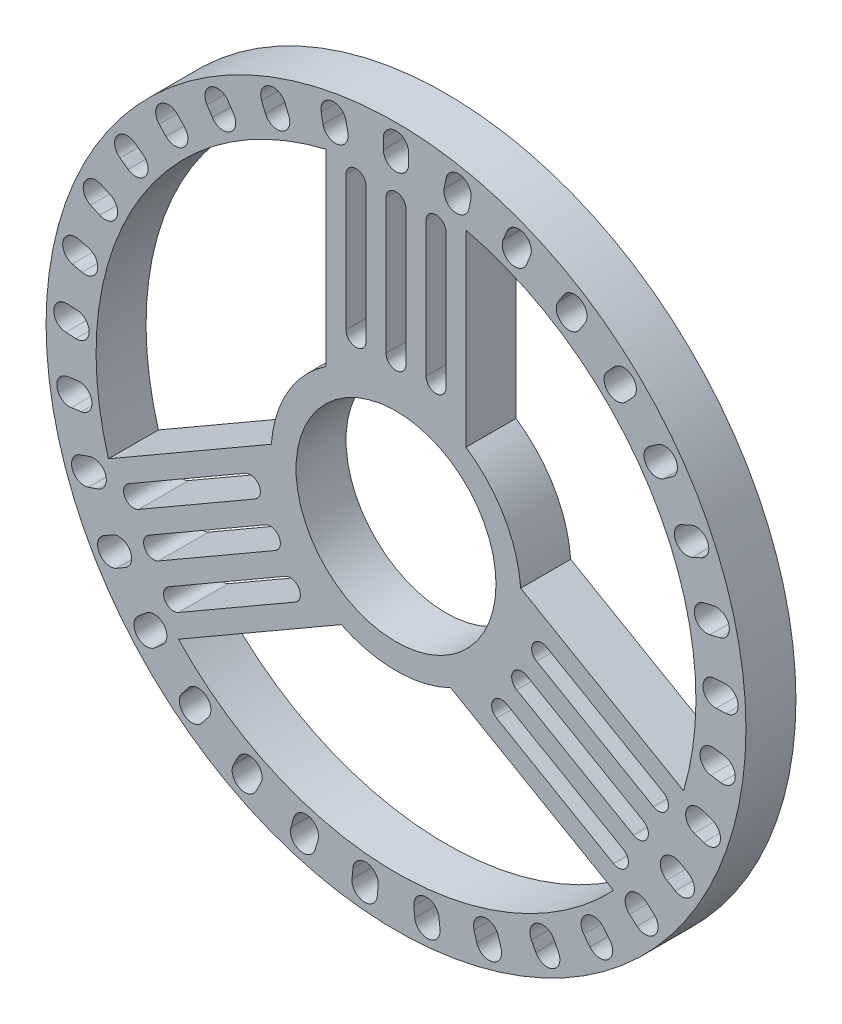
from build123d import *

# Parameters (mm, degrees)
SKETCH_1_R      = 17.5
SKETCH_1_R_2    = 5
EXTRUDE_2_DEPTH = 2.5


with BuildPart() as part:
    # 草图1 → 凸台-拉伸2 (new body)
    with BuildSketch(Plane.XY):
        Circle(SKETCH_1_R)
        with BuildLine():
            Line((14.381805097, -4.26188716), (6.234347779, 0.442049516))
            ThreePointArc((6.234347779, 0.442049516), (5.412658774, 3.125), (3.5, 5.178078794))
            Line((3.5, 5.178078794), (3.5, 14.585952146))
            ThreePointArc((3.5, 14.585952146), (12.990381057, 7.5), (14.381805097, -4.26188716))
        make_face(mode=Mode.SUBTRACT)
        with BuildLine():
            Line((2.734347779, -5.62012831), (10.881805097, -10.324064986))
            ThreePointArc((10.881805097, -10.324064986), (0, -15), (-10.881805097, -10.324064986))
            Line((-10.881805097, -10.324064986), (-2.734347779, -5.62012831))
            ThreePointArc((-2.734347779, -5.62012831), (0, -6.25), (2.734347779, -5.62012831))
        make_face(mode=Mode.SUBTRACT)
        with BuildLine():
            Line((-3.5, 14.585952146), (-3.5, 5.178078794))
            ThreePointArc((-3.5, 5.178078794), (-5.412658774, 3.125), (-6.234347779, 0.442049516))
            Line((-6.234347779, 0.442049516), (-14.381805097, -4.26188716))
            ThreePointArc((-14.381805097, -4.26188716), (-12.990381057, 7.5), (-3.5, 14.585952146))
        make_face(mode=Mode.SUBTRACT)
        with BuildLine():
            Line((-11.373072369, -8.299039919), (-5.532643333, -4.927066643))
            ThreePointArc((-5.532643333, -4.927066643), (-4.850509276, -5.109843913), (-5.033286546, -5.79197797))
            Line((-5.033286546, -5.79197797), (-10.873715582, -9.163951246))
            ThreePointArc((-10.873715582, -9.163951246), (-11.555849639, -8.981173976), (-11.373072369, -8.299039919))
        make_face(mode=Mode.SUBTRACT)
        with BuildLine():
            ThreePointArc((-11.873715582, -7.431900439), (-12.555849639, -7.249123169), (-12.373072369, -6.566989112))
            Line((-12.373072369, -6.566989112), (-6.532643333, -3.195015836))
            ThreePointArc((-6.532643333, -3.195015836), (-5.850509276, -3.377793105), (-6.033286546, -4.059927163))
            Line((-6.033286546, -4.059927163), (-11.873715582, -7.431900439))
        make_face(mode=Mode.SUBTRACT)
        with BuildLine():
            ThreePointArc((-12.873715582, -5.699849631), (-13.555849639, -5.517072361), (-13.373072369, -4.834938304))
            Line((-13.373072369, -4.834938304), (-7.532643333, -1.462965028))
            ThreePointArc((-7.532643333, -1.462965028), (-6.850509276, -1.645742298), (-7.033286546, -2.327876355))
            Line((-7.033286546, -2.327876355), (-12.873715582, -5.699849631))
        make_face(mode=Mode.SUBTRACT)
        with BuildLine():
            ThreePointArc((11.373072369, -8.299039919), (11.555849639, -8.981173976), (10.873715582, -9.163951246))
            Line((10.873715582, -9.163951246), (5.033286546, -5.79197797))
            ThreePointArc((5.033286546, -5.79197797), (4.850509276, -5.109843913), (5.532643333, -4.927066643))
            Line((5.532643333, -4.927066643), (11.373072369, -8.299039919))
        make_face(mode=Mode.SUBTRACT)
        with BuildLine():
            ThreePointArc((12.373072369, -6.566989112), (12.555849639, -7.249123169), (11.873715582, -7.431900439))
            Line((11.873715582, -7.431900439), (6.033286546, -4.059927163))
            ThreePointArc((6.033286546, -4.059927163), (5.850509276, -3.377793105), (6.532643333, -3.195015836))
            Line((6.532643333, -3.195015836), (12.373072369, -6.566989112))
        make_face(mode=Mode.SUBTRACT)
        with BuildLine():
            ThreePointArc((13.373072369, -4.834938304), (13.555849639, -5.517072361), (12.873715582, -5.699849631))
            Line((12.873715582, -5.699849631), (7.033286546, -2.327876355))
            ThreePointArc((7.033286546, -2.327876355), (6.850509276, -1.645742298), (7.532643333, -1.462965028))
            Line((7.532643333, -1.462965028), (13.373072369, -4.834938304))
        make_face(mode=Mode.SUBTRACT)
        Circle(SKETCH_1_R_2, mode=Mode.SUBTRACT)
        with BuildLine():
            ThreePointArc((-2.499356787, 13.99888955), (-2, 14.498246338), (-1.500643213, 13.99888955))
            Line((-1.500643213, 13.99888955), (-1.500643213, 7.254942998))
            ThreePointArc((-1.500643213, 7.254942998), (-2, 6.755586211), (-2.499356787, 7.254942998))
            Line((-2.499356787, 7.254942998), (-2.499356787, 13.99888955))
        make_face(mode=Mode.SUBTRACT)
        with BuildLine():
            ThreePointArc((-0.499356787, 13.99888955), (0, 14.498246338), (0.499356787, 13.99888955))
            Line((0.499356787, 13.99888955), (0.499356787, 7.254942998))
            ThreePointArc((0.499356787, 7.254942998), (0, 6.755586211), (-0.499356787, 7.254942998))
            Line((-0.499356787, 7.254942998), (-0.499356787, 13.99888955))
        make_face(mode=Mode.SUBTRACT)
        with BuildLine():
            Line((2.499356787, 13.99888955), (2.499356787, 7.254942998))
            ThreePointArc((2.499356787, 7.254942998), (2, 6.755586211), (1.500643213, 7.254942998))
            Line((1.500643213, 7.254942998), (1.500643213, 13.99888955))
            ThreePointArc((1.500643213, 13.99888955), (2, 14.498246338), (2.499356787, 13.99888955))
        make_face(mode=Mode.SUBTRACT)
        with BuildLine():
            ThreePointArc((-9.701417984, -13.361669033), (-10.591416242, -13.468081352), (-10.697828562, -12.578083094))
            Line((-10.697828562, -12.578083094), (-10.388749068, -12.185056546))
            ThreePointArc((-10.388749068, -12.185056546), (-9.49875081, -12.078644227), (-9.392338491, -12.968642486))
            Line((-9.392338491, -12.968642486), (-9.701417984, -13.361669033))
        make_face(mode=Mode.SUBTRACT)
        with BuildLine():
            ThreePointArc((-12.054813214, -11.284200841), (-12.948866708, -11.220256873), (-12.88492274, -10.326203379))
            Line((-12.88492274, -10.326203379), (-12.507047953, -9.998773012))
            ThreePointArc((-12.507047953, -9.998773012), (-11.612994459, -10.06271698), (-11.676938426, -10.956770474))
            Line((-11.676938426, -10.956770474), (-12.054813214, -11.284200841))
        make_face(mode=Mode.SUBTRACT)
        with BuildLine():
            ThreePointArc((-4.040454636, -16.010197893), (-4.827151016, -16.439766616), (-5.256719739, -15.653070236))
            Line((-5.256719739, -15.653070236), (-5.115853461, -15.17332375))
            ThreePointArc((-5.115853461, -15.17332375), (-4.329157081, -14.743755026), (-3.899588358, -15.530451406))
            Line((-3.899588358, -15.530451406), (-4.040454636, -16.010197893))
        make_face(mode=Mode.SUBTRACT)
        with BuildLine():
            ThreePointArc((-6.997388231, -14.956211692), (-7.851164398, -15.22913428), (-8.124086986, -14.375358113))
            Line((-8.124086986, -14.375358113), (-7.894973725, -13.930940389))
            ThreePointArc((-7.894973725, -13.930940389), (-7.041197558, -13.658017801), (-6.76827497, -14.511793968))
            Line((-6.76827497, -14.511793968), (-6.997388231, -14.956211692))
        make_face(mode=Mode.SUBTRACT)
        with BuildLine():
            ThreePointArc((-0.937488484, -16.485533828), (-1.62867182, -17.056222953), (-2.199360945, -16.365039617))
            Line((-2.199360945, -16.365039617), (-2.151832924, -15.867303656))
            ThreePointArc((-2.151832924, -15.867303656), (-1.460649588, -15.29661453), (-0.889960462, -15.987797866))
            Line((-0.889960462, -15.987797866), (-0.937488484, -16.485533828))
        make_face(mode=Mode.SUBTRACT)
        with BuildLine():
            ThreePointArc((-13.972516085, -8.79889223), (-14.838311393, -8.566903077), (-14.606322239, -7.70110777))
            Line((-14.606322239, -7.70110777), (-14.173309538, -7.45110777))
            ThreePointArc((-14.173309538, -7.45110777), (-13.30751423, -7.683096923), (-13.539503384, -8.54889223))
            Line((-13.539503384, -8.54889223), (-13.972516085, -8.79889223))
        make_face(mode=Mode.SUBTRACT)
        with BuildLine():
            ThreePointArc((-15.385215821, -5.995568729), (-16.191460843, -5.603919083), (-15.799811197, -4.79767406))
            Line((-15.799811197, -4.79767406), (-15.327310787, -4.634140079))
            ThreePointArc((-15.327310787, -4.634140079), (-14.521065765, -5.025789725), (-14.912715411, -5.832034748))
            Line((-14.912715411, -5.832034748), (-15.385215821, -5.995568729))
        make_face(mode=Mode.SUBTRACT)
        with BuildLine():
            ThreePointArc((-16.241853771, -2.975549753), (-16.959408712, -2.438394852), (-16.422253811, -1.72083991))
            Line((-16.422253811, -1.72083991), (-15.92734309, -1.649682491))
            ThreePointArc((-15.92734309, -1.649682491), (-15.209788149, -2.186837392), (-15.74694305, -2.904392334))
            Line((-15.74694305, -2.904392334), (-16.241853771, -2.975549753))
        make_face(mode=Mode.SUBTRACT)
        with BuildLine():
            ThreePointArc((2.199360945, -16.365039617), (1.62867182, -17.056222953), (0.937488484, -16.485533828))
            Line((0.937488484, -16.485533828), (0.889960462, -15.987797866))
            ThreePointArc((0.889960462, -15.987797866), (1.460649588, -15.29661453), (2.151832924, -15.867303656))
            Line((2.151832924, -15.867303656), (2.199360945, -16.365039617))
        make_face(mode=Mode.SUBTRACT)
        with BuildLine():
            ThreePointArc((5.256719739, -15.653070236), (4.827151016, -16.439766616), (4.040454636, -16.010197893))
            Line((4.040454636, -16.010197893), (3.899588358, -15.530451406))
            ThreePointArc((3.899588358, -15.530451406), (4.329157081, -14.743755026), (5.115853461, -15.17332375))
            Line((5.115853461, -15.17332375), (5.256719739, -15.653070236))
        make_face(mode=Mode.SUBTRACT)
        with BuildLine():
            ThreePointArc((8.124086986, -14.375358113), (7.851164398, -15.22913428), (6.997388231, -14.956211692))
            Line((6.997388231, -14.956211692), (6.76827497, -14.511793968))
            ThreePointArc((6.76827497, -14.511793968), (7.041197558, -13.658017801), (7.894973725, -13.930940389))
            Line((7.894973725, -13.930940389), (8.124086986, -14.375358113))
        make_face(mode=Mode.SUBTRACT)
        with BuildLine():
            ThreePointArc((10.697828562, -12.578083094), (10.591416242, -13.468081352), (9.701417984, -13.361669033))
            Line((9.701417984, -13.361669033), (9.392338491, -12.968642486))
            ThreePointArc((9.392338491, -12.968642486), (9.49875081, -12.078644227), (10.388749068, -12.185056546))
            Line((10.388749068, -12.185056546), (10.697828562, -12.578083094))
        make_face(mode=Mode.SUBTRACT)
        with BuildLine():
            ThreePointArc((12.88492274, -10.326203379), (12.948866708, -11.220256873), (12.054813214, -11.284200841))
            Line((12.054813214, -11.284200841), (11.676938426, -10.956770474))
            ThreePointArc((11.676938426, -10.956770474), (11.612994459, -10.06271698), (12.507047953, -9.998773012))
            Line((12.507047953, -9.998773012), (12.88492274, -10.326203379))
        make_face(mode=Mode.SUBTRACT)
        with BuildLine():
            ThreePointArc((14.606322239, -7.70110777), (14.838311393, -8.566903077), (13.972516085, -8.79889223))
            Line((13.972516085, -8.79889223), (13.539503384, -8.54889223))
            ThreePointArc((13.539503384, -8.54889223), (13.30751423, -7.683096923), (14.173309538, -7.45110777))
            Line((14.173309538, -7.45110777), (14.606322239, -7.70110777))
        make_face(mode=Mode.SUBTRACT)
        with BuildLine():
            ThreePointArc((15.799811197, -4.79767406), (16.191460843, -5.603919083), (15.385215821, -5.995568729))
            Line((15.385215821, -5.995568729), (14.912715411, -5.832034748))
            ThreePointArc((14.912715411, -5.832034748), (14.521065765, -5.025789725), (15.327310787, -4.634140079))
            Line((15.327310787, -4.634140079), (15.799811197, -4.79767406))
        make_face(mode=Mode.SUBTRACT)
        with BuildLine():
            ThreePointArc((16.422253811, -1.72083991), (16.959408712, -2.438394852), (16.241853771, -2.975549753))
            Line((16.241853771, -2.975549753), (15.74694305, -2.904392334))
            ThreePointArc((15.74694305, -2.904392334), (15.209788149, -2.186837392), (15.92734309, -1.649682491))
            Line((15.92734309, -1.649682491), (16.422253811, -1.72083991))
        make_face(mode=Mode.SUBTRACT)
        with BuildLine():
            ThreePointArc((-16.511468808, 0.152013344), (-17.114399363, 0.815259322), (-16.451153385, 1.418189878))
            Line((-16.451153385, 1.418189878), (-15.951719716, 1.39439892))
            ThreePointArc((-15.951719716, 1.39439892), (-15.34878916, 0.731152942), (-16.012035138, 0.128222387))
            Line((-16.012035138, 0.128222387), (-16.511468808, 0.152013344))
        make_face(mode=Mode.SUBTRACT)
        with BuildLine():
            ThreePointArc((-16.184316342, 3.274082283), (-16.65083103, 4.0394479), (-15.885465413, 4.505962588))
            Line((-15.885465413, 4.505962588), (-15.399559629, 4.388083121))
            ThreePointArc((-15.399559629, 4.388083121), (-14.933044941, 3.622717504), (-15.698410557, 3.156202816))
            Line((-15.698410557, 3.156202816), (-16.184316342, 3.274082283))
        make_face(mode=Mode.SUBTRACT)
        with BuildLine():
            ThreePointArc((-15.272220515, 6.277817358), (-15.58545828, 7.117640306), (-14.745635332, 7.430878071))
            Line((-14.745635332, 7.430878071), (-14.290819334, 7.223170565))
            ThreePointArc((-14.290819334, 7.223170565), (-13.977581569, 6.383347616), (-14.817404517, 6.070109851))
            Line((-14.817404517, 6.070109851), (-15.272220515, 6.277817358))
        make_face(mode=Mode.SUBTRACT)
        with BuildLine():
            ThreePointArc((-13.808146848, 9.054655757), (-13.95678646, 9.938582647), (-13.07285957, 10.087222259))
            Line((-13.07285957, 10.087222259), (-12.665571594, 9.797193804))
            ThreePointArc((-12.665571594, 9.797193804), (-12.516931981, 8.913266914), (-13.400858872, 8.764627302))
            Line((-13.400858872, 8.764627302), (-13.808146848, 9.054655757))
        make_face(mode=Mode.SUBTRACT)
        with BuildLine():
            ThreePointArc((-11.845010777, 11.504235304), (-11.823680014, 12.400318716), (-10.927596602, 12.378987953))
            Line((-10.927596602, 12.378987953), (-10.582557096, 12.017120934))
            ThreePointArc((-10.582557096, 12.017120934), (-10.603887859, 11.121037522), (-11.499971271, 11.142368285))
            Line((-11.499971271, 11.142368285), (-11.845010777, 11.504235304))
        make_face(mode=Mode.SUBTRACT)
        with BuildLine():
            ThreePointArc((-9.453765154, 13.538021814), (-9.263234965, 14.413874958), (-8.387381822, 14.223344769))
            Line((-8.387381822, 14.223344769), (-8.117061413, 13.802718003))
            ThreePointArc((-8.117061413, 13.802718003), (-8.307591602, 12.926864859), (-9.183444746, 13.117395048))
            Line((-9.183444746, 13.117395048), (-9.453765154, 13.538021814))
        make_face(mode=Mode.SUBTRACT)
        with BuildLine():
            ThreePointArc((-6.720835828, 15.082508943), (-6.36799247, 15.906476204), (-5.544025209, 15.553632846))
            Line((-5.544025209, 15.553632846), (-5.358193981, 15.08944888))
            ThreePointArc((-5.358193981, 15.08944888), (-5.711037339, 14.265481619), (-6.5350046, 14.618324977))
            Line((-6.5350046, 14.618324977), (-6.720835828, 15.082508943))
        make_face(mode=Mode.SUBTRACT)
        with BuildLine():
            ThreePointArc((-3.744997983, 16.081874901), (-3.242594135, 16.824175956), (-2.500293081, 16.321772108))
            Line((-2.500293081, 16.321772108), (-2.405667459, 15.83080776))
            ThreePointArc((-2.405667459, 15.83080776), (-2.908071306, 15.088506705), (-3.650372361, 15.590910553))
            Line((-3.650372361, 15.590910553), (-3.744997983, 16.081874901))
        make_face(mode=Mode.SUBTRACT)
        with BuildLine():
            Line((9.453765154, 13.538021814), (9.183444746, 13.117395048))
            ThreePointArc((9.183444746, 13.117395048), (8.307591602, 12.926864859), (8.117061413, 13.802718003))
            Line((8.117061413, 13.802718003), (8.387381822, 14.223344769))
            ThreePointArc((8.387381822, 14.223344769), (9.263234965, 14.413874958), (9.453765154, 13.538021814))
        make_face(mode=Mode.SUBTRACT)
        with BuildLine():
            ThreePointArc((16.451153385, 1.418189878), (17.114399363, 0.815259322), (16.511468808, 0.152013344))
            Line((16.511468808, 0.152013344), (16.012035138, 0.128222387))
            ThreePointArc((16.012035138, 0.128222387), (15.34878916, 0.731152942), (15.951719716, 1.39439892))
            Line((15.951719716, 1.39439892), (16.451153385, 1.418189878))
        make_face(mode=Mode.SUBTRACT)
        with BuildLine():
            ThreePointArc((15.885465413, 4.505962588), (16.65083103, 4.0394479), (16.184316342, 3.274082283))
            Line((16.184316342, 3.274082283), (15.698410557, 3.156202816))
            ThreePointArc((15.698410557, 3.156202816), (14.933044941, 3.622717504), (15.399559629, 4.388083121))
            Line((15.399559629, 4.388083121), (15.885465413, 4.505962588))
        make_face(mode=Mode.SUBTRACT)
        with BuildLine():
            ThreePointArc((14.745635332, 7.430878071), (15.58545828, 7.117640306), (15.272220515, 6.277817358))
            Line((15.272220515, 6.277817358), (14.817404517, 6.070109851))
            ThreePointArc((14.817404517, 6.070109851), (13.977581569, 6.383347616), (14.290819334, 7.223170565))
            Line((14.290819334, 7.223170565), (14.745635332, 7.430878071))
        make_face(mode=Mode.SUBTRACT)
        with BuildLine():
            ThreePointArc((-0.633806154, 16.5), (0, 17.133806154), (0.633806154, 16.5))
            Line((0.633806154, 16.5), (0.633806154, 16))
            ThreePointArc((0.633806154, 16), (0, 15.366193846), (-0.633806154, 16))
            Line((-0.633806154, 16), (-0.633806154, 16.5))
        make_face(mode=Mode.SUBTRACT)
        with BuildLine():
            ThreePointArc((2.500293081, 16.321772108), (3.242594135, 16.824175956), (3.744997983, 16.081874901))
            Line((3.744997983, 16.081874901), (3.650372361, 15.590910553))
            ThreePointArc((3.650372361, 15.590910553), (2.908071306, 15.088506705), (2.405667459, 15.83080776))
            Line((2.405667459, 15.83080776), (2.500293081, 16.321772108))
        make_face(mode=Mode.SUBTRACT)
        with BuildLine():
            ThreePointArc((5.544025209, 15.553632846), (6.36799247, 15.906476204), (6.720835828, 15.082508943))
            Line((6.720835828, 15.082508943), (6.5350046, 14.618324977))
            ThreePointArc((6.5350046, 14.618324977), (5.711037339, 14.265481619), (5.358193981, 15.08944888))
            Line((5.358193981, 15.08944888), (5.544025209, 15.553632846))
        make_face(mode=Mode.SUBTRACT)
        with BuildLine():
            ThreePointArc((10.927596602, 12.378987953), (11.823680014, 12.400318716), (11.845010777, 11.504235304))
            Line((11.845010777, 11.504235304), (11.499971271, 11.142368285))
            ThreePointArc((11.499971271, 11.142368285), (10.603887859, 11.121037522), (10.582557096, 12.017120934))
            Line((10.582557096, 12.017120934), (10.927596602, 12.378987953))
        make_face(mode=Mode.SUBTRACT)
        with BuildLine():
            ThreePointArc((13.07285957, 10.087222259), (13.95678646, 9.938582647), (13.808146848, 9.054655757))
            Line((13.808146848, 9.054655757), (13.400858872, 8.764627302))
            ThreePointArc((13.400858872, 8.764627302), (12.516931981, 8.913266914), (12.665571594, 9.797193804))
            Line((12.665571594, 9.797193804), (13.07285957, 10.087222259))
        make_face(mode=Mode.SUBTRACT)
    extrude(amount=EXTRUDE_2_DEPTH)


solid = part.part
